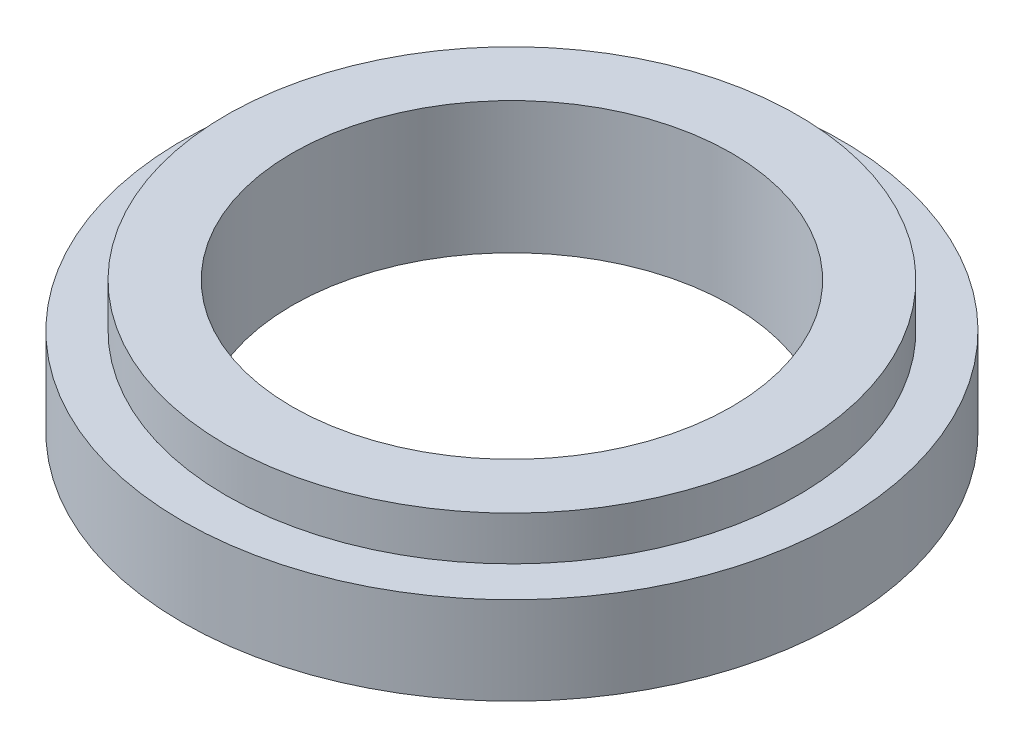
from build123d import *

# Parameters (mm, degrees)
SKETCH2_R           = 3.75
SKETCH2_R_2         = 2.5
BOSS_EXTRUDE1_DEPTH = 1.5
SKETCH3_R           = 3.75
SKETCH3_R_2         = 3.25
CUT_EXTRUDE1_DEPTH  = 0.5


with BuildPart() as part:
    # Sketch2 → Boss-Extrude1 (new body)
    with BuildSketch(Plane(origin=(0, 0, 0), x_dir=(1, 0, 0), z_dir=(0, 1, 0))):
        Circle(SKETCH2_R)
        Circle(SKETCH2_R_2, mode=Mode.SUBTRACT)
    extrude(amount=BOSS_EXTRUDE1_DEPTH)

    # Sketch3 → Cut-Extrude1 (cut)
    with BuildSketch(Plane(origin=(0, 1.5, 0), x_dir=(1, 0, 0), z_dir=(0, 1, 0))):
        Circle(SKETCH3_R)
        Circle(SKETCH3_R_2, mode=Mode.SUBTRACT)
    extrude(amount=-CUT_EXTRUDE1_DEPTH, mode=Mode.SUBTRACT)


solid = part.part
